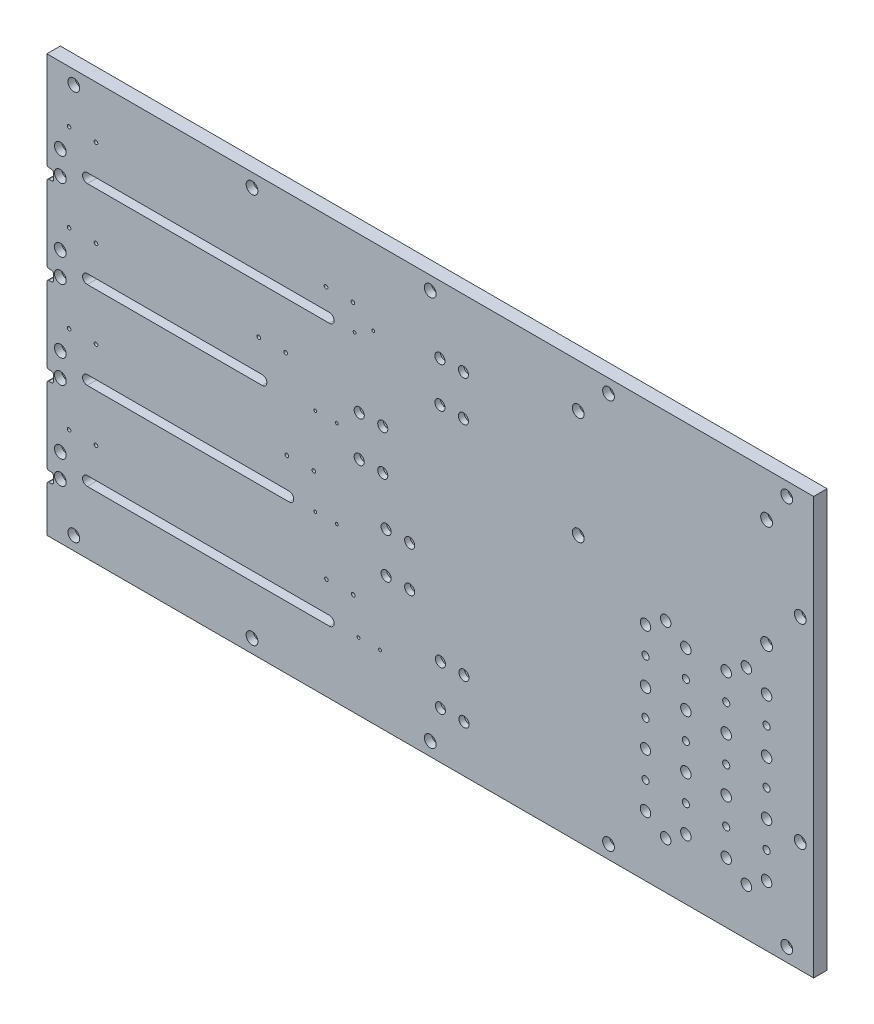
from build123d import *

# Parameters (mm, degrees)
SKETCH1_W                                        = 723.9
SKETCH1_H                                        = 393.7
BOSS_EXTRUDE1_DEPTH                              = 12.7
CUT_EXTRUDE1_DEPTH                               = 12.7
SKETCH5_W                                        = 6.35
SKETCH5_H                                        = 9.525
CUT_EXTRUDE2_DEPTH                               = 13.7
FILLET1_R                                        = 2.032
F_6_32_TAPPED_HOLE1_D                            = 2.7051
CBORE_FOR_1_4_SOCKET_HEAD_CAP_SCREW1_D           = 6.7564
CBORE_FOR_1_4_SOCKET_HEAD_CAP_SCREW1_CBORE_D     = 11.1125
CBORE_FOR_1_4_SOCKET_HEAD_CAP_SCREW1_CBORE_DEPTH = 6.731
SKETCH15_R                                       = 3.3655
SKETCH15_R_2                                     = 4.953
SKETCH15_R_3                                     = 4.7625
CUT_EXTRUDE9_DEPTH                               = 12.7
CBORE_FOR_1_4_SOCKET_HEAD_CAP_SCREW2_D           = 6.7564
CBORE_FOR_1_4_SOCKET_HEAD_CAP_SCREW2_CBORE_D     = 11.1125
CBORE_FOR_1_4_SOCKET_HEAD_CAP_SCREW2_CBORE_DEPTH = 6.731
F_6_32_TAPPED_HOLE2_D                            = 2.7051
CBORE_FOR_10_SOCKET_HEAD_CAP_SCREW1_D            = 5.1054
CBORE_FOR_10_SOCKET_HEAD_CAP_SCREW1_CBORE_D      = 9.525
CBORE_FOR_10_SOCKET_HEAD_CAP_SCREW1_CBORE_DEPTH  = 5.207
F_8_32_TAPPED_HOLE1_D                            = 3.4544
SKETCH28_R                                       = 3.3655
SKETCH28_R_2                                     = 3.302
CUT_EXTRUDE10_DEPTH                              = 13.7
SKETCH29_R                                       = 5.5626
CUT_EXTRUDE11_DEPTH                              = 6.731


with BuildPart() as part:
    # Sketch1 → Boss-Extrude1 (new body)
    with BuildSketch(Plane.XY):
        with Locations((361.95, -196.85)):
            Rectangle(SKETCH1_W, SKETCH1_H)
    extrude(amount=-BOSS_EXTRUDE1_DEPTH)

    # Sketch2 → Cut-Extrude1 (cut)
    with BuildSketch(Plane.XY):
        with BuildLine():
            Line((38.1, -78.105), (266.7, -78.105))
            ThreePointArc((266.7, -78.105), (271.145, -82.55), (266.7, -86.995))
            Line((266.7, -86.995), (38.1, -86.995))
            ThreePointArc((38.1, -86.995), (33.655, -82.55), (38.1, -78.105))
        make_face()
        with BuildLine():
            Line((38.1, -160.655), (203.2, -160.655))
            ThreePointArc((203.2, -160.655), (207.645, -165.1), (203.2, -169.545))
            Line((203.2, -169.545), (38.1, -169.545))
            ThreePointArc((38.1, -169.545), (33.655, -165.1), (38.1, -160.655))
        make_face()
        with BuildLine():
            Line((38.1, -243.205), (228.6, -243.205))
            ThreePointArc((228.6, -243.205), (233.045, -247.65), (228.6, -252.095))
            Line((228.6, -252.095), (38.1, -252.095))
            ThreePointArc((38.1, -252.095), (33.655, -247.65), (38.1, -243.205))
        make_face()
        with BuildLine():
            Line((38.1, -325.755), (266.7, -325.755))
            ThreePointArc((266.7, -325.755), (271.145, -330.2), (266.7, -334.645))
            Line((266.7, -334.645), (38.1, -334.645))
            ThreePointArc((38.1, -334.645), (33.655, -330.2), (38.1, -325.755))
        make_face()
    extrude(amount=-CUT_EXTRUDE1_DEPTH, mode=Mode.SUBTRACT)

    # Sketch5 → Cut-Extrude2 (cut, through all)
    with BuildSketch(Plane.XY):
        with Locations((3.175, -179.5375)):
            Rectangle(SKETCH5_W, SKETCH5_H)
        with Locations((3.175, -96.9875)):
            Rectangle(SKETCH5_W, SKETCH5_H)
        with Locations((3.175, -262.0875)):
            Rectangle(SKETCH5_W, SKETCH5_H)
        with Locations((3.175, -344.6375)):
            Rectangle(SKETCH5_W, SKETCH5_H)
    extrude(amount=-CUT_EXTRUDE2_DEPTH, mode=Mode.SUBTRACT)

    # Fillet1
    fillet1_edges = [part.edges().sort_by_distance(p)[0] for p in [
        (0, -349.4, -6.35),
        (0, -339.875, -6.35),
        (6.35, -339.875, -6.35),
        (6.35, -349.4, -6.35),
        (0, -266.85, -6.35),
        (0, -257.325, -6.35),
        (6.35, -257.325, -6.35),
        (6.35, -266.85, -6.35),
        (0, -101.75, -6.35),
        (0, -92.225, -6.35),
        (6.35, -92.225, -6.35),
        (6.35, -101.75, -6.35),
        (0, -184.3, -6.35),
        (0, -174.775, -6.35),
        (6.35, -174.775, -6.35),
        (6.35, -184.3, -6.35),
    ]]
    fillet(fillet1_edges, radius=FILLET1_R)

    # #6-32 Tapped Hole1 (through all)
    with Locations(Plane(origin=(0, 0, -12.7), x_dir=(-1, 0, 0), z_dir=(0, 0, -1))):
        with Locations((-20.955, -131.7625), (-46.355, -131.7625), (-46.355, -214.3125), (-20.955, -214.3125), (-46.355, -296.994599595), (-20.955, -296.994599595)):
            Hole(F_6_32_TAPPED_HOLE1_D / 2)

    # CBORE for 1/4 Socket Head Cap Screw1 (through all)
    with Locations(Plane.XY):
        with Locations((25.4, -381), (193.675, -381), (361.95, -381), (530.225, -381), (698.5, -381), (711.2, -288.925), (711.2, -104.775), (698.5, -12.7), (530.225, -12.7), (361.95, -12.7), (193.675, -12.7), (25.4, -12.7)):
            CounterBoreHole(CBORE_FOR_1_4_SOCKET_HEAD_CAP_SCREW1_D / 2, CBORE_FOR_1_4_SOCKET_HEAD_CAP_SCREW1_CBORE_D / 2, CBORE_FOR_1_4_SOCKET_HEAD_CAP_SCREW1_CBORE_DEPTH)

    # Sketch15 → Cut-Extrude9 (cut)
    with BuildSketch(Plane(origin=(0, 0, -12.7), x_dir=(-1, 0, 0), z_dir=(0, 0, -1))):
        with Locations((-565.15, -209.55)):
            Circle(SKETCH15_R)
        with Locations((-565.15, -184.15)):
            Circle(SKETCH15_R_2)
        with Locations((-565.15, -234.95)):
            Circle(SKETCH15_R_2)
        with Locations((-584.2, -171.45)):
            Circle(SKETCH15_R_2)
        with Locations((-603.25, -184.15)):
            Circle(SKETCH15_R_2)
        with Locations((-603.25, -209.55)):
            Circle(SKETCH15_R)
        with Locations((-603.25, -234.95)):
            Circle(SKETCH15_R_2)
        with Locations((-603.25, -260.35)):
            Circle(SKETCH15_R)
        with Locations((-565.15, -260.35)):
            Circle(SKETCH15_R)
        with Locations((-565.15, -285.75)):
            Circle(SKETCH15_R_3)
        with Locations((-565.15, -311.15)):
            Circle(SKETCH15_R)
        with Locations((-565.15, -336.55)):
            Circle(SKETCH15_R_2)
        with Locations((-584.2, -349.25)):
            Circle(SKETCH15_R_2)
        with Locations((-603.25, -336.55)):
            Circle(SKETCH15_R_2)
        with Locations((-603.25, -311.15)):
            Circle(SKETCH15_R)
        with Locations((-603.25, -285.75)):
            Circle(SKETCH15_R_2)
        with Locations((-641.35, -184.15)):
            Circle(SKETCH15_R_2)
        with Locations((-641.35, -209.55)):
            Circle(SKETCH15_R)
        with Locations((-641.35, -234.95)):
            Circle(SKETCH15_R_2)
        with Locations((-641.35, -260.35)):
            Circle(SKETCH15_R)
        with Locations((-660.4, -171.45)):
            Circle(SKETCH15_R_2)
        with Locations((-679.45, -184.15)):
            Circle(SKETCH15_R_2)
        with Locations((-679.45, -209.55)):
            Circle(SKETCH15_R)
        with Locations((-679.45, -234.95)):
            Circle(SKETCH15_R_2)
        with Locations((-679.45, -260.35)):
            Circle(SKETCH15_R)
        with Locations((-679.45, -285.75)):
            Circle(SKETCH15_R_2)
        with Locations((-641.35, -285.75)):
            Circle(SKETCH15_R_2)
        with Locations((-641.35, -311.15)):
            Circle(SKETCH15_R)
        with Locations((-679.45, -311.15)):
            Circle(SKETCH15_R)
        with Locations((-679.45, -336.55)):
            Circle(SKETCH15_R_2)
        with Locations((-660.4, -349.25)):
            Circle(SKETCH15_R_2)
        with Locations((-641.35, -336.55)):
            Circle(SKETCH15_R_2)
    extrude(amount=-CUT_EXTRUDE9_DEPTH, mode=Mode.SUBTRACT)

    # CBORE for 1/4 Socket Head Cap Screw2 (through all)
    with Locations(Plane.XY):
        with Locations((12.7, -319.0875), (12.7, -341.3125), (12.7, -258.7625), (12.7, -236.5375), (12.7, -176.2125), (12.7, -153.9875), (12.7, -93.6625), (12.7, -71.4375)):
            CounterBoreHole(CBORE_FOR_1_4_SOCKET_HEAD_CAP_SCREW2_D / 2, CBORE_FOR_1_4_SOCKET_HEAD_CAP_SCREW2_CBORE_D / 2, CBORE_FOR_1_4_SOCKET_HEAD_CAP_SCREW2_CBORE_DEPTH)

    # #6-32 Tapped Hole2 (through all)
    with Locations(Plane.XY):
        with Locations((253.365, -247.65), (273.685, -247.65), (253.365, -165.1), (273.685, -165.1), (290.480681693, -82.55), (308.078317898, -72.39), (294.24, -330.2), (314.56, -330.2)):
            Hole(F_6_32_TAPPED_HOLE2_D / 2)

    # CBORE for #10 Socket Head Cap Screw1 (through all)
    with Locations(Plane.XY):
        with Locations((371.075, -101.6), (393.3, -101.6), (393.3, -63.5), (371.075, -63.5), (317.1, -146.05), (294.875, -146.05), (294.875, -184.15), (317.1, -184.15), (320.275, -228.6), (342.5, -228.6), (342.5, -266.7), (320.275, -266.7), (371.530586253, -349.25), (393.755586253, -349.25), (393.755586253, -311.15), (371.530586253, -311.15)):
            CounterBoreHole(CBORE_FOR_10_SOCKET_HEAD_CAP_SCREW1_D / 2, CBORE_FOR_10_SOCKET_HEAD_CAP_SCREW1_CBORE_D / 2, CBORE_FOR_10_SOCKET_HEAD_CAP_SCREW1_CBORE_DEPTH)

    # #8-32 Tapped Hole1 (through all)
    with Locations(Plane(origin=(0, 0, -12.7), x_dir=(-1, 0, 0), z_dir=(0, 0, -1))):
        with Locations((-289.282858359, -297.6375), (-263.882858359, -297.6375), (-226.588522521, -215.0875), (-251.988522521, -215.0875), (-225.425, -131.7625), (-200.025, -131.7625), (-288.925, -58.7375), (-263.525, -58.7375), (-46.355, -49.2125), (-20.955, -49.2125), (-20.955, -131.7625), (-46.355, -131.7625), (-46.355, -214.3125), (-20.955, -214.3125), (-20.955, -296.994599595), (-46.355, -296.994599595)):
            Hole(F_8_32_TAPPED_HOLE1_D / 2)

    # Sketch28 → Cut-Extrude10 (cut, through all)
    with BuildSketch(Plane(origin=(0, 0, -12.7), x_dir=(-1, 0, 0), z_dir=(0, 0, -1))):
        with Locations((-501.65, -41.275)):
            Circle(SKETCH28_R)
        with Locations((-501.65, -142.875)):
            Circle(SKETCH28_R_2)
        with Locations((-679.45, -142.875)):
            Circle(SKETCH28_R)
        with Locations((-679.45, -41.275)):
            Circle(SKETCH28_R)
    extrude(amount=-CUT_EXTRUDE10_DEPTH, mode=Mode.SUBTRACT)

    # Sketch29 → Cut-Extrude11 (cut)
    with BuildSketch(Plane.XY):
        with Locations((501.65, -41.275)):
            Circle(SKETCH29_R)
        with Locations((501.65, -142.875)):
            Circle(SKETCH29_R)
        with Locations((679.45, -142.875)):
            Circle(SKETCH29_R)
        with Locations((679.45, -41.275)):
            Circle(SKETCH29_R)
    extrude(amount=-CUT_EXTRUDE11_DEPTH, mode=Mode.SUBTRACT)


solid = part.part
